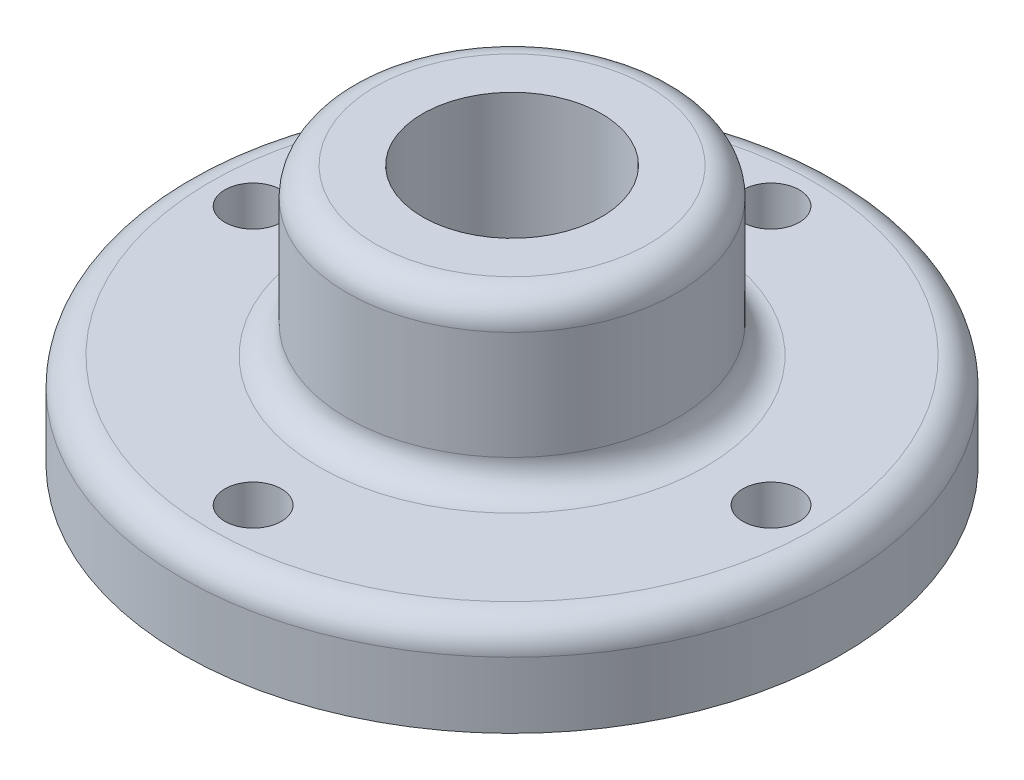
from build123d import *

# Parameters (mm, degrees)
SKETCH1_R           = 70
SKETCH1_R_2         = 6
BOSS_EXTRUDE1_DEPTH = 20
SKETCH2_R           = 35
BOSS_EXTRUDE2_DEPTH = 35
SKETCH3_R           = 19
CUT_EXTRUDE1_DEPTH  = 56
FILLET1_R           = 6


with BuildPart() as part:
    # Sketch1 → Boss-Extrude1 (new body)
    with BuildSketch(Plane(origin=(0, 0, 0), x_dir=(1, 0, 0), z_dir=(0, 1, 0))):
        Circle(SKETCH1_R)
        with Locations((0, 55)):
            Circle(SKETCH1_R_2, mode=Mode.SUBTRACT)
        with Locations((55, 0)):
            Circle(SKETCH1_R_2, mode=Mode.SUBTRACT)
        with Locations((0, -55)):
            Circle(SKETCH1_R_2, mode=Mode.SUBTRACT)
        with Locations((-55, 0)):
            Circle(SKETCH1_R_2, mode=Mode.SUBTRACT)
    extrude(amount=BOSS_EXTRUDE1_DEPTH)

    # Sketch2 → Boss-Extrude2 (add)
    with BuildSketch(Plane(origin=(0, 20, 0), x_dir=(1, 0, 0), z_dir=(0, 1, 0))):
        Circle(SKETCH2_R)
    extrude(amount=BOSS_EXTRUDE2_DEPTH)

    # Sketch3 → Cut-Extrude1 (cut, through all)
    with BuildSketch(Plane(origin=(0, 55, 0), x_dir=(1, 0, 0), z_dir=(0, 1, 0))):
        Circle(SKETCH3_R)
    extrude(amount=-CUT_EXTRUDE1_DEPTH, mode=Mode.SUBTRACT)

    # Fillet1
    fillet1_edges = [part.edges().sort_by_distance(p)[0] for p in [
        (-35, 20, 0),
        (-35, 55, 0),
        (-70, 20, 0),
    ]]
    fillet(fillet1_edges, radius=FILLET1_R)


solid = part.part
